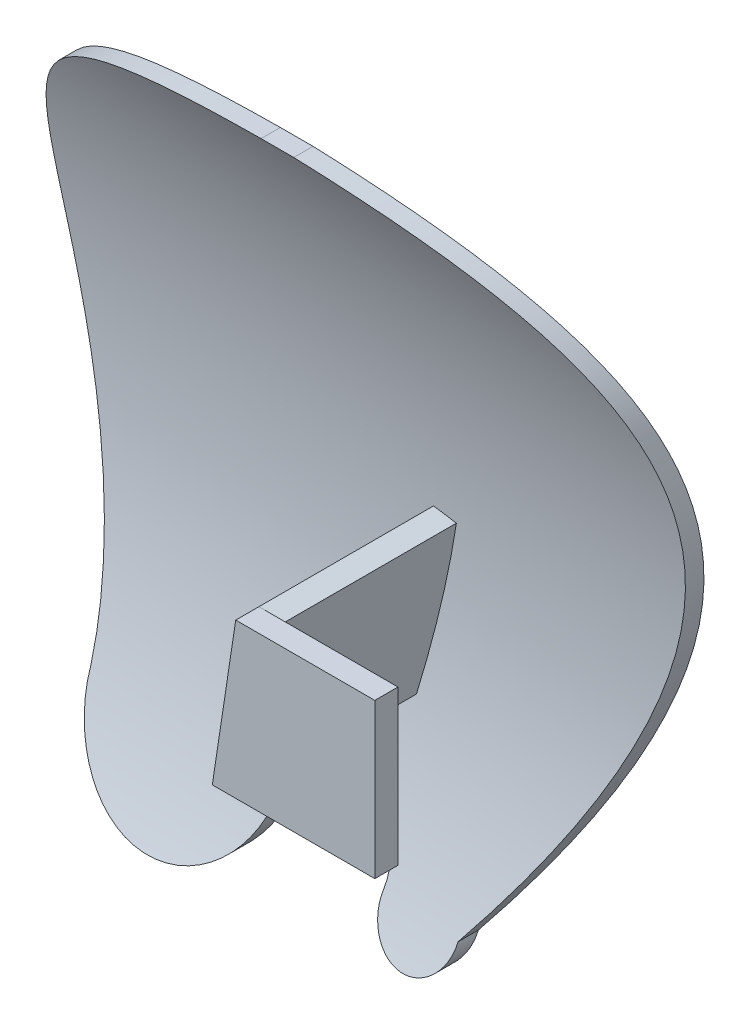
from build123d import *

# Parameters (mm, degrees)
SKETCH2_W               = 90
SKETCH2_H               = 90
BOSS_EXTRUDE1_DEPTH     = 20
CUT_EXTRUDE1_DEPTH      = 67.708320321
CUT_EXTRUDE1_DEPTH_BACK = 67.708320321
CUT_EXTRUDE2_DEPTH      = 67.708320486
CUT_EXTRUDE2_DEPTH_BACK = 67.708320486
BOSS_EXTRUDE2_START     = 7.5
BOSS_EXTRUDE2_DEPTH     = 26
BOSS_EXTRUDE3_START     = 4
SKETCH6_W               = 3
SKETCH6_H               = 20
BOSS_EXTRUDE3_DEPTH     = 20
CUT_EXTRUDE3_START      = 30
CUT_EXTRUDE3_DEPTH      = 10


with BuildPart() as part:
    # Sketch2 → Boss-Extrude1 (new body)
    with BuildSketch(Plane.XY):
        Rectangle(SKETCH2_W, SKETCH2_H)
    extrude(amount=BOSS_EXTRUDE1_DEPTH)

    # Sketch3 → Cut-Extrude1 (cut, two sides)
    with BuildSketch(Plane(origin=(0, 0, 0), x_dir=(0, 0, -1), z_dir=(1, 0, 0))) as cut_extrude1_sk:
        with BuildLine():
            Line((0, -45), (0, 45))
            Line((0, 45), (-17.5, 45))
            add(Edge.make_bspline(
                [(-17.5, 45), (6.726056833, 3.093816892), (-17.5, -45)],
                knots=[0, 0, 0, 1, 1, 1], degree=2))
            Line((-17.5, -45), (0, -45))
        make_face()
        with BuildLine():
            add(Edge.make_bspline(
                [(-20, 45), (4.227639313, 5.03468062), (-20, -45)],
                knots=[0, 0, 0, 1, 1, 1], degree=2))
            Line((-20, -45), (-20, 45))
        make_face()
    extrude(amount=CUT_EXTRUDE1_DEPTH, mode=Mode.SUBTRACT)
    extrude(cut_extrude1_sk.sketch, amount=-CUT_EXTRUDE1_DEPTH_BACK, mode=Mode.SUBTRACT)

    # Sketch4 → Cut-Extrude2 (cut, two sides)
    with BuildSketch(Plane.XY) as cut_extrude2_sk:
        with BuildLine():
            Line((0, -41.973736842), (0, -45))
            Line((0, -45), (45, -45))
            Line((45, -45), (45, 45))
            Line((45, 45), (0, 45))
            add(Edge.make_bspline(
                [(17.375058461, -36.236668515), (37.115061452, -9.091765806), (61.513002786, 39.355563534), (0, 45)],
                knots=[0, 0, 0, 0, 1, 1, 1, 1], degree=3))
            ThreePointArc((17.375058461, -36.236668515), (12.021587761, -41.224158712), (7.425035075, -35.531495855))
            ThreePointArc((7.425035075, -35.531495855), (4.915119907, -40.138681352), (0, -41.973736842))
        make_face()
        with BuildLine():
            Line((-45, -45), (0, -45))
            Line((0, -45), (0, -41.973736842))
            ThreePointArc((0, -41.973736842), (-5.751088308, -39.287777066), (-7.382925452, -33.153732383))
            ThreePointArc((-7.382925452, -33.153732383), (-20.792123146, -43.404847745), (-32.187801105, -30.953724389))
            add(Edge.make_bspline(
                [(-32.187801105, -30.953724389), (-34.107884409, -0.978450852), (-64.097466043, 43.988968502), (-4.230485268, 45)],
                knots=[0, 0, 0, 0, 0.977737851, 0.977737851, 0.977737851, 0.977737851], degree=3))
            Line((-4.230485268, 45), (-45, 45))
            Line((-45, 45), (-45, -45))
        make_face()
        with BuildLine():
            ThreePointArc((-7.382925452, -33.153732383), (-5.751088308, -39.287777066), (0, -41.973736842))
            Line((0, -41.973736842), (0, -26.973736842))
            ThreePointArc((0, -26.973736842), (-4.814040224, -28.722648535), (-7.382925452, -33.153732383))
        make_face()
        with BuildLine():
            Line((0, -26.973736842), (0, -41.973736842))
            ThreePointArc((0, -41.973736842), (4.915119907, -40.138681352), (7.425035075, -35.531495855))
            ThreePointArc((7.425035075, -35.531495855), (7.481235295, -35.003942903), (7.5, -34.473736842))
            ThreePointArc((7.5, -34.473736842), (5.303300859, -29.170435983), (0, -26.973736842))
        make_face()
    extrude(amount=CUT_EXTRUDE2_DEPTH, mode=Mode.SUBTRACT)
    extrude(cut_extrude2_sk.sketch, amount=-CUT_EXTRUDE2_DEPTH_BACK, mode=Mode.SUBTRACT)

    # Sketch5 → Boss-Extrude2 (add)
    with BuildSketch(Plane.XY.offset(BOSS_EXTRUDE2_START)):
        Polygon((5.987927079, -17.143883964), (8.953511265, 2.40618792), (5.98744237, 2.856116036), (2.953607811, -17.143883964), align=None)
    extrude(amount=BOSS_EXTRUDE2_DEPTH)

    # Sketch6 → Boss-Extrude3 (add)
    with BuildSketch(Plane(origin=(0, 0, 0), x_dir=(0, 0, -1), z_dir=(1, 0, 0)).offset(BOSS_EXTRUDE3_START)):
        with Locations((-32, -7.143883964)):
            Rectangle(SKETCH6_W, SKETCH6_H)
    extrude(amount=BOSS_EXTRUDE3_DEPTH)

    # Sketch7 → Cut-Extrude3 (cut)
    with BuildSketch(Plane.XY.offset(CUT_EXTRUDE3_START)):
        Polygon((4, -10.245734651), (5.98744237, 2.856116036), (3.019616762, 2.856116036), (3.582073592, -13.000838136), align=None)
    extrude(amount=CUT_EXTRUDE3_DEPTH, mode=Mode.SUBTRACT)


solid = part.part
